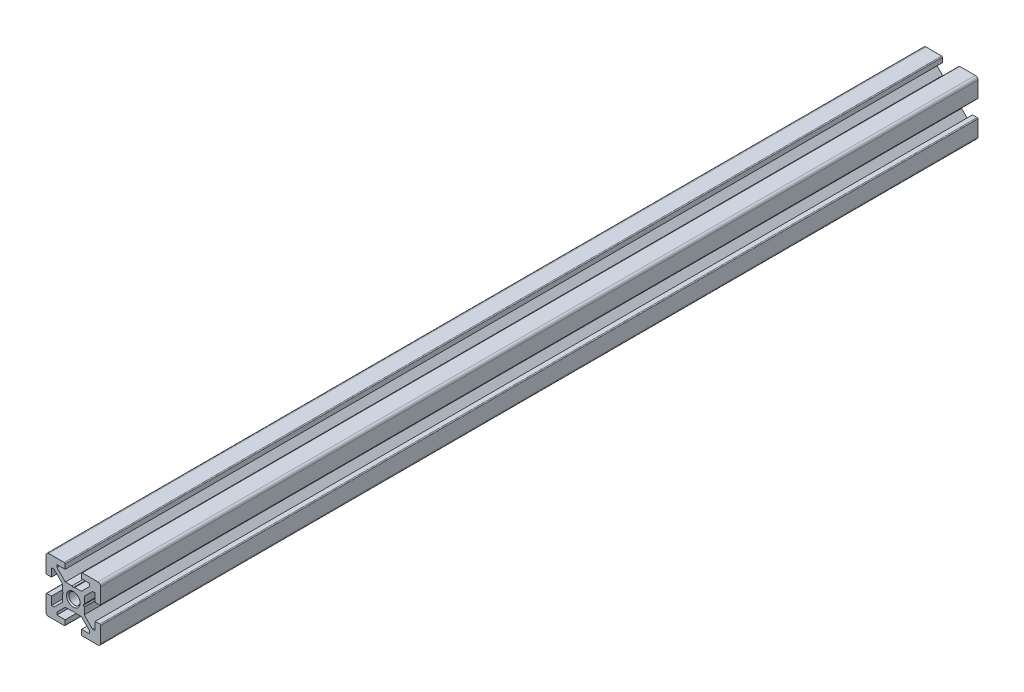
from build123d import *

# Parameters (mm, degrees)
BOSS_EXTRUDE1_DEPTH = 321


with BuildPart() as part:
    # Sketch1 → Boss-Extrude1 (new body)
    with BuildSketch(Plane.XY):
        with BuildLine():
            Line((-10, 9), (-10, 3.29999995))
            ThreePointArc((-10, 3.29999995), (-9.912132049, 3.087867916), (-9.7, 3))
            Line((-9.7, 3), (-8, 3))
            Line((-8, 3), (-8, 6))
            Line((-8, 6), (-7.060677, 6))
            Line((-7.060677, 6), (-4, 2.93932965))
            Line((-4, 2.93932965), (-4, 0.519615242))
            Line((-4, 0.519615242), (-3.699996283, -6.437e-06))
            Line((-3.699996283, -6.437e-06), (-4, -0.519628117))
            Line((-4, -0.519628117), (-4, -2.93933725))
            Line((-4, -2.93933725), (-7.0606695, -6))
            Line((-7.0606695, -6), (-8, -6))
            Line((-8, -6), (-8, -3))
            Line((-8, -3), (-9.7, -3))
            ThreePointArc((-9.7, -3), (-9.912132049, -3.087867916), (-10, -3.29999995))
            Line((-10, -3.29999995), (-10, -9))
            ThreePointArc((-10, -9), (-9.707106781, -9.707106781), (-9, -10))
            Line((-9, -10), (-3.29999995, -10))
            ThreePointArc((-3.29999995, -10), (-3.087867916, -9.912132049), (-3, -9.7))
            Line((-3, -9.7), (-3, -8))
            Line((-3, -8), (-6, -8))
            Line((-6, -8), (-6, -7.0606515))
            Line((-6, -7.0606515), (-2.9393489, -4))
            Line((-2.9393489, -4), (-0.519615242, -4))
            Line((-0.519615242, -4), (6.437e-06, -3.699996283))
            Line((6.437e-06, -3.699996283), (0.519628117, -4))
            Line((0.519628117, -4), (2.9393227, -4))
            Line((2.9393227, -4), (6, -7.060677))
            Line((6, -7.060677), (6, -8))
            Line((6, -8), (3, -8))
            Line((3, -8), (3, -9.7))
            ThreePointArc((3, -9.7), (3.087867916, -9.912132049), (3.29999995, -10))
            Line((3.29999995, -10), (9, -10))
            ThreePointArc((9, -10), (9.707106781, -9.707106781), (10, -9))
            Line((10, -9), (10, -3.29999995))
            ThreePointArc((10, -3.29999995), (9.912132049, -3.087867916), (9.7, -3))
            Line((9.7, -3), (8, -3))
            Line((8, -3), (8, -6))
            Line((8, -6), (7.0606435, -6))
            Line((7.0606435, -6), (4, -2.9393482))
            Line((4, -2.9393482), (4, -0.519615242))
            Line((4, -0.519615242), (3.699996283, 6.437e-06))
            Line((3.699996283, 6.437e-06), (4, 0.519628117))
            Line((4, 0.519628117), (4, 2.9393401))
            Line((4, 2.9393401), (7.060651, 6))
            Line((7.060651, 6), (8, 6))
            Line((8, 6), (8, 3))
            Line((8, 3), (9.7, 3))
            ThreePointArc((9.7, 3), (9.912132049, 3.087867916), (10, 3.29999995))
            Line((10, 3.29999995), (10, 9))
            ThreePointArc((10, 9), (9.707106781, 9.707106781), (9, 10))
            Line((9, 10), (3.29999995, 10))
            ThreePointArc((3.29999995, 10), (3.087867916, 9.912132049), (3, 9.7))
            Line((3, 9.7), (3, 8))
            Line((3, 8), (6, 8))
            Line((6, 8), (6, 7.060669))
            Line((6, 7.060669), (2.9393308, 4))
            Line((2.9393308, 4), (0.519615242, 4))
            Line((0.519615242, 4), (-6.437e-06, 3.699996283))
            Line((-6.437e-06, 3.699996283), (-0.519628117, 4))
            Line((-0.519628117, 4), (-2.93935655, 4))
            Line((-2.93935655, 4), (-6, 7.0606435))
            Line((-6, 7.0606435), (-6, 8))
            Line((-6, 8), (-3, 8))
            Line((-3, 8), (-3, 9.7))
            ThreePointArc((-3, 9.7), (-3.087867966, 9.912132034), (-3.3, 10))
            Line((-3.3, 10), (-9, 10))
            ThreePointArc((-9, 10), (-9.707106781, 9.707106781), (-10, 9))
        make_face()
    extrude(amount=-BOSS_EXTRUDE1_DEPTH)

    # Sketch2 → Cut-Revolve1 (revolve, cut)
    with BuildSketch(Plane(origin=(0, 0, 0), x_dir=(0, 0, -1), z_dir=(1, 0, 0))):
        Polygon((0, 0), (0, 2.5), (0.433, 2.067), (321, 2.067), (321, 0), align=None)
    revolve(axis=Axis((0, 0, -321), (0, 0, 1)), mode=Mode.SUBTRACT)

    # Sketch3 → Cut-Revolve2 (revolve, cut)
    with BuildSketch(Plane(origin=(0, 0, 0), x_dir=(0, 0, -1), z_dir=(1, 0, 0))):
        Polygon((0, 0), (0, 2.067), (320.567, 2.067), (321, 2.5), (321, 0), align=None)
    revolve(axis=Axis((0, 0, -321), (0, 0, 1)), mode=Mode.SUBTRACT)


solid = part.part
